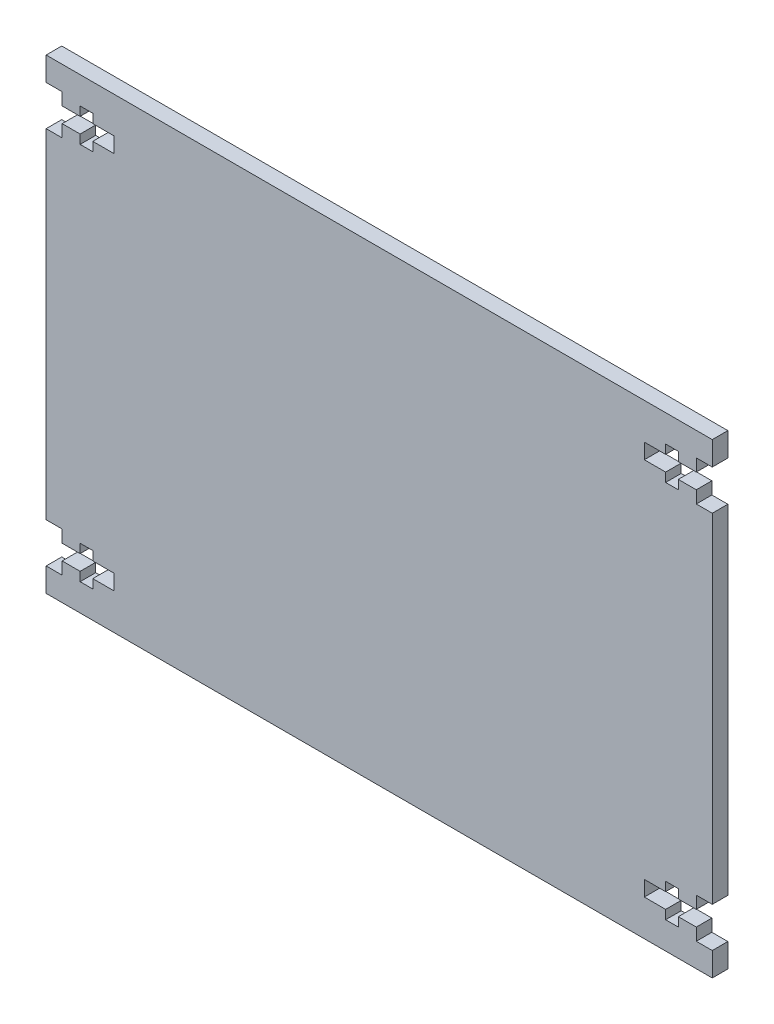
from build123d import *

# Parameters (mm, degrees)
BOSS_EXTRUDE1_DEPTH = 2.9718


with BuildPart() as part:
    # Sketch1 → Boss-Extrude1 (new body)
    with BuildSketch(Plane.XY):
        Polygon((-127, 88.9), (0, 88.9), (0, 84.361375025), (-3.048, 84.361375025), (-3.048, 82.011875025), (-6.477, 82.011875025), (-6.477, 83.726375025), (-8.89, 83.726375025), (-8.89, 82.011875025), (-12.954, 82.011875025), (-12.954, 79.090875025), (-8.89, 79.090875025), (-8.89, 77.376375025), (-6.477, 77.376375025), (-6.477, 79.090875025), (-3.048, 79.090875025), (-3.048, 76.741375025), (0, 76.741375025), (0, 12.158624975), (-3.048, 12.158624975), (-3.048, 9.809124975), (-6.477, 9.809124975), (-6.477, 11.523624975), (-8.89, 11.523624975), (-8.89, 9.809124975), (-12.954, 9.809124975), (-12.954, 6.888124975), (-8.89, 6.888124975), (-8.89, 5.173624975), (-6.477, 5.173624975), (-6.477, 6.888124975), (-3.048, 6.888124975), (-3.048, 4.538624975), (0, 4.538624975), (0, 0), (-127, 0), (-127, 4.538624975), (-123.952, 4.538624975), (-123.952, 6.888124975), (-120.523, 6.888124975), (-120.523, 5.173624975), (-118.11, 5.173624975), (-118.11, 6.888124975), (-114.046, 6.888124975), (-114.046, 9.809124975), (-118.11, 9.809124975), (-118.11, 11.523624975), (-120.523, 11.523624975), (-120.523, 9.809124975), (-123.952, 9.809124975), (-123.952, 12.158624975), (-127, 12.158624975), (-127, 76.741375025), (-123.952, 76.741375025), (-123.952, 79.090875025), (-120.523, 79.090875025), (-120.523, 77.376375025), (-118.11, 77.376375025), (-118.11, 79.090875025), (-114.046, 79.090875025), (-114.046, 82.011875025), (-118.11, 82.011875025), (-118.11, 83.726375025), (-120.523, 83.726375025), (-120.523, 82.011875025), (-123.952, 82.011875025), (-123.952, 84.361375025), (-127, 84.361375025), align=None)
    extrude(amount=BOSS_EXTRUDE1_DEPTH)


solid = part.part
